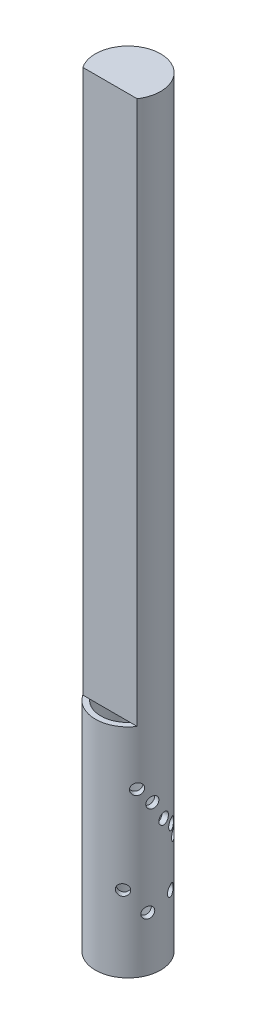
from build123d import *

# Parameters (mm, degrees)
SKETCH1_R                            = 15
SKETCH1_R_2                          = 12.5
BOSS_EXTRUDE1_DEPTH                  = 100
BOSS_EXTRUDE2_DEPTH                  = 250
F_8_0_199_DIAMETER_HOLE1_D           = 5.0546
F_8_0_199_DIAMETER_HOLE1_ON_FACE_2_D = 5.0546
F_8_0_199_DIAMETER_HOLE1_ON_FACE_3_D = 5.0546
F_8_0_199_DIAMETER_HOLE1_ON_FACE_4_D = 5.0546
F_8_0_199_DIAMETER_HOLE1_ON_FACE_5_D = 5.0546
F_8_0_199_DIAMETER_HOLE1_ON_FACE_6_D = 5.0546
F_8_0_199_DIAMETER_HOLE1_ON_FACE_7_D = 5.0546
F_8_0_199_DIAMETER_HOLE1_ON_FACE_8_D = 5.0546


with BuildPart() as part:
    # Sketch1 → Boss-Extrude1 (new body)
    with BuildSketch(Plane(origin=(0, 0, 0), x_dir=(1, 0, 0), z_dir=(0, 1, 0))):
        with Locations(Location((0, 0, 0), (0, 0, 270))):
            Circle(SKETCH1_R)
        with Locations(Location((0, 0, 0), (0, 0, 270))):
            Circle(SKETCH1_R_2, mode=Mode.SUBTRACT)
    extrude(amount=BOSS_EXTRUDE1_DEPTH)

    # Sketch5 → Boss-Extrude2 (add)
    with BuildSketch(Plane(origin=(0, 100, 0), x_dir=(1, 0, 0), z_dir=(0, 1, 0))):
        with BuildLine():
            Line((-12.5, -8.291561976), (12.5, -8.291561976))
            ThreePointArc((12.5, -8.291561976), (0, 15), (-12.5, -8.291561976))
        make_face()
    extrude(amount=BOSS_EXTRUDE2_DEPTH)

    # #8 (0.199) Diameter Hole1 (through all)
    with Locations(Plane(origin=(13.739642772, 28.320151961, -6.018489554), x_dir=(0.401232636905, 0, 0.915976184779), z_dir=(0.915976184779, 0, -0.401232636905))):
        with Locations((0, 0)):
            Hole(F_8_0_199_DIAMETER_HOLE1_D / 2)

    # #8 (0.199) Diameter Hole1 on face 2 (through all)
    with Locations(Plane(origin=(-9.376165476, 34.972710695, -11.708438024), x_dir=(-0.780562569499, 0, 0.625077655253), z_dir=(-0.625077655253, 0, -0.780562569499))):
        with Locations((0, 0)):
            Hole(F_8_0_199_DIAMETER_HOLE1_ON_FACE_2_D / 2)

    # #8 (0.199) Diameter Hole1 on face 3 (through all)
    with Locations(Plane(origin=(12.213234919, 48.590015564, -8.708438024), x_dir=(0.580562683122, 0, 0.814215555591), z_dir=(0.814215555591, 0, -0.580562683122))):
        with Locations((0, 0)):
            Hole(F_8_0_199_DIAMETER_HOLE1_ON_FACE_3_D / 2)

    # #8 (0.199) Diameter Hole1 on face 4 (through all)
    with Locations(Plane(origin=(13.416290817, 54.378019541, -6.708438024), x_dir=(0.447229195439, 0, 0.89441939086), z_dir=(0.89441939086, 0, -0.447229195439))):
        with Locations((0, 0)):
            Hole(F_8_0_199_DIAMETER_HOLE1_ON_FACE_4_D / 2)

    # #8 (0.199) Diameter Hole1 on face 5 (through all)
    with Locations(Plane(origin=(14.902390396, 59.625580238, -1.708438024), x_dir=(0.113895963561, 0, 0.993492682149), z_dir=(0.993492682149, 0, -0.113895963561))):
        with Locations((0, 0)):
            Hole(F_8_0_199_DIAMETER_HOLE1_ON_FACE_5_D / 2)

    # #8 (0.199) Diameter Hole1 on face 6 (through all)
    with Locations(Plane(origin=(14.63439851, 68.336228716, 3.291561976), x_dir=(-0.219436929769, 0, 0.975626687752), z_dir=(0.975626687752, 0, 0.219436929769))):
        with Locations((0, 0)):
            Hole(F_8_0_199_DIAMETER_HOLE1_ON_FACE_6_D / 2)

    # #8 (0.199) Diameter Hole1 on face 7 (through all)
    with Locations(Plane(origin=(12.5, 75, 8.291561976), x_dir=(-0.552771091945, 0, 0.833333138612), z_dir=(0.833333138612, 0, 0.552771091945))):
        with Locations((0, 0)):
            Hole(F_8_0_199_DIAMETER_HOLE1_ON_FACE_7_D / 2)

    # #8 (0.199) Diameter Hole1 on face 8 (through all)
    with Locations(Plane(origin=(-14.163519694, 25, -4.939100107), x_dir=(0.329272926942, 0, -0.944234790496), z_dir=(-0.944234790496, 0, -0.329272926942))):
        with Locations((0, 0)):
            Hole(F_8_0_199_DIAMETER_HOLE1_ON_FACE_8_D / 2)


solid = part.part
